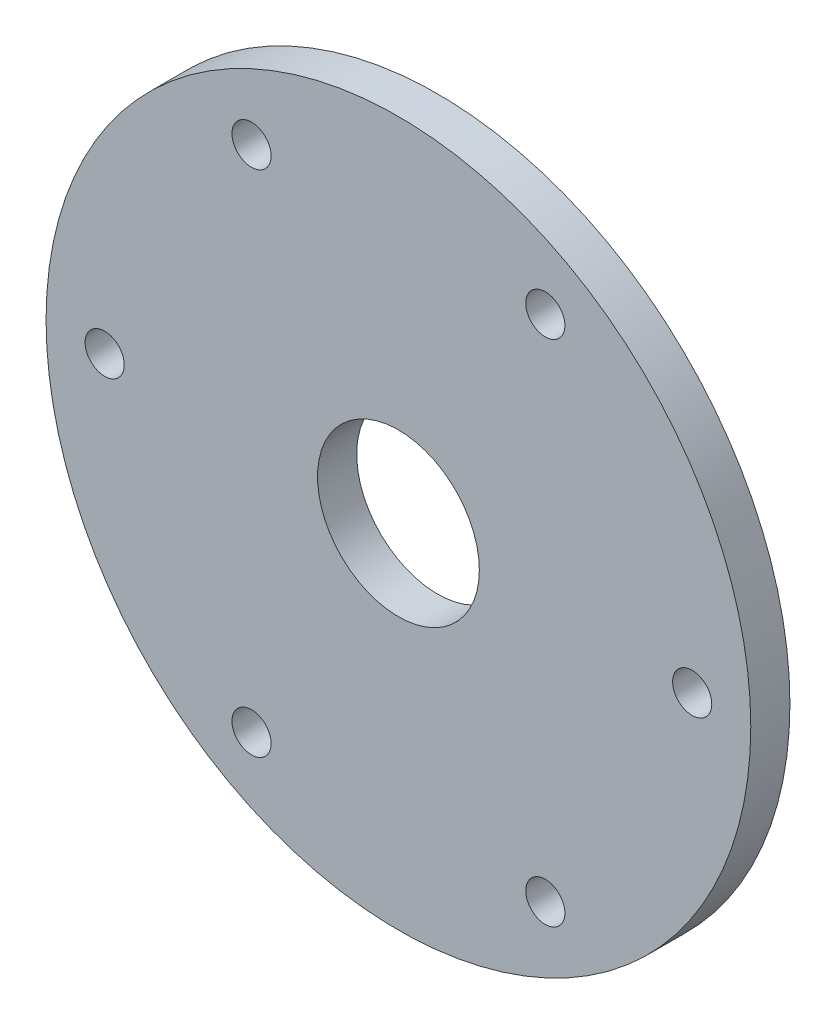
from build123d import *

# Parameters (mm, degrees)
SKETCH_2_R      = 27
SKETCH_2_R_2    = 6.2
SKETCH_2_R_3    = 1.5
EXTRUDE_1_DEPTH = 3


with BuildPart() as part:
    # 草图2 → 凸台-拉伸1 (new body)
    with BuildSketch(Plane.XY):
        Circle(SKETCH_2_R)
        Circle(SKETCH_2_R_2, mode=Mode.SUBTRACT)
        with Locations((22.51, 0)):
            Circle(SKETCH_2_R_3, mode=Mode.SUBTRACT)
        with Locations((11.255, -19.494231839)):
            Circle(SKETCH_2_R_3, mode=Mode.SUBTRACT)
        with Locations((-11.255, -19.494231839)):
            Circle(SKETCH_2_R_3, mode=Mode.SUBTRACT)
        with Locations((-22.51, 0)):
            Circle(SKETCH_2_R_3, mode=Mode.SUBTRACT)
        with Locations((-11.255, 19.494231839)):
            Circle(SKETCH_2_R_3, mode=Mode.SUBTRACT)
        with Locations((11.255, 19.494231839)):
            Circle(SKETCH_2_R_3, mode=Mode.SUBTRACT)
    extrude(amount=EXTRUDE_1_DEPTH)


solid = part.part
